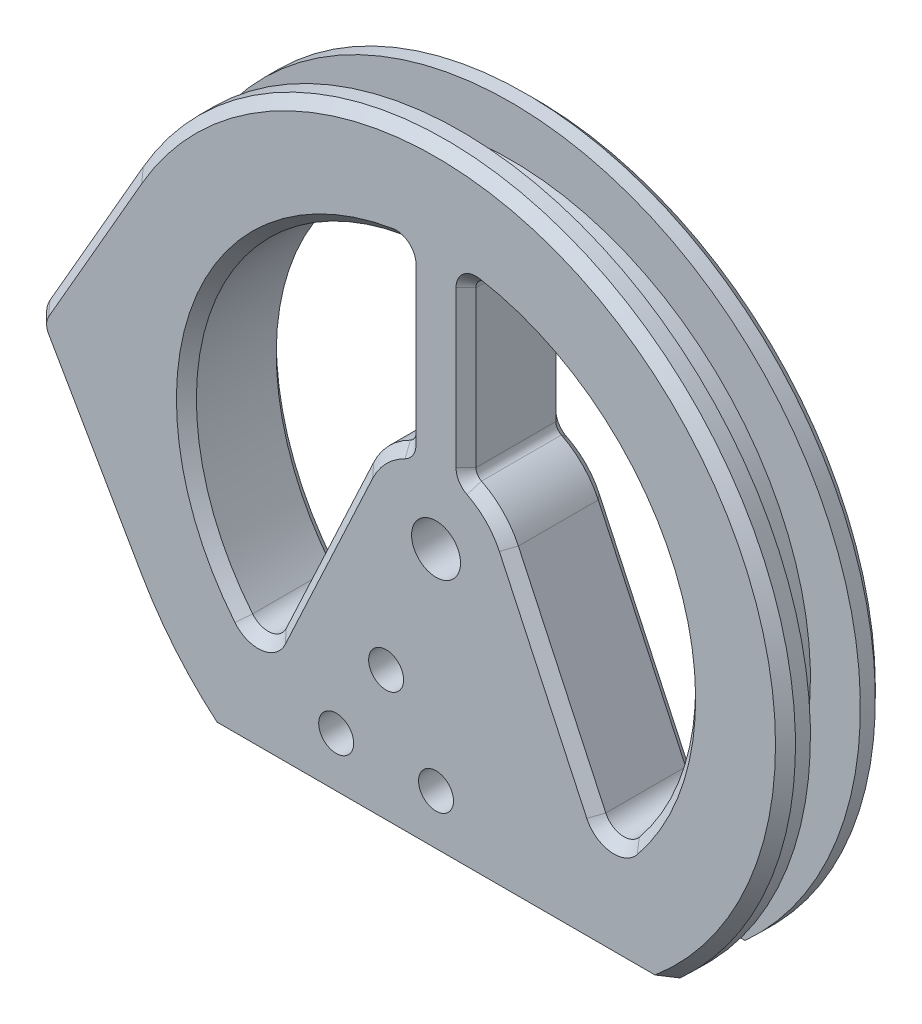
from build123d import *

# Parameters (mm, degrees)
EXTRUDE_1_DEPTH     = 10
SKETCH_2_R          = 2.45
EXTRUDE_2_DEPTH     = 10
SKETCH_3_R          = 1.75
CUT_EXTRUDE_1_DEPTH = 11
EXTRUDE_3_DEPTH     = 2.5
EXTRUDE_4_DEPTH     = 2.5
EXTRUDE_5_REACH     = 9.5
SKETCH_6_R          = 2.5
FILLET_1_R          = 2
SKETCH_7_W          = 6
SKETCH_7_H          = 22
EXTRUDE_6_DEPTH     = 10
FILLET_2_R          = 1
CHAMFER_1_SIZE      = 1
CHAMFER_2_SIZE      = 1
SKETCH_8_R          = 1.75
CUT_EXTRUDE_2_DEPTH = 11


with BuildPart() as part:
    # ｽｹｯﾁ1 → ﾎﾞｽ - 押し出し1 (new body)
    with BuildSketch(Plane.XY):
        with BuildLine():
            Line((-15, -25.980762114), (15, -25.980762114))
            ThreePointArc((15, -25.980762114), (0, 30), (-15, -25.980762114))
        make_face()
        with BuildLine():
            Line((-13.594396682, -20.980762114), (13.594396682, -20.980762114))
            ThreePointArc((13.594396682, -20.980762114), (0, 25), (-13.594396682, -20.980762114))
        make_face(mode=Mode.SUBTRACT)
    extrude(amount=EXTRUDE_1_DEPTH)

    # ｽｹｯﾁ2 → ﾎﾞｽ - 押し出し2 (add)
    with BuildSketch(Plane.XY):
        with BuildLine():
            Line((-13.594396682, -20.980762114), (13.594396682, -20.980762114))
            ThreePointArc((13.594396682, -20.980762114), (15.495156387, -19.618871745), (17.260361171, -18.085351317))
            Line((17.260361171, -18.085351317), (7.250462296, 3.380946094))
            ThreePointArc((7.250462296, 3.380946094), (0, 8), (-7.250462296, 3.380946094))
            Line((-7.250462296, 3.380946094), (-17.260361171, -18.085351317))
            ThreePointArc((-17.260361171, -18.085351317), (-15.495156387, -19.618871745), (-13.594396682, -20.980762114))
        make_face()
        Circle(SKETCH_2_R, mode=Mode.SUBTRACT)
    extrude(amount=EXTRUDE_2_DEPTH)

    # ｽｹｯﾁ3 → ｶｯﾄ - 押し出し1 (cut, through all)
    with BuildSketch(Plane.XY.offset(10)):
        with Locations((0, -20.980762114)):
            Circle(SKETCH_3_R)
        with Locations((-10, -20.980762114)):
            Circle(SKETCH_3_R)
    extrude(amount=-CUT_EXTRUDE_1_DEPTH, mode=Mode.SUBTRACT)

    # ｽｹｯﾁ4 → ﾎﾞｽ - 押し出し3 (add)
    with BuildSketch(Plane.XY):
        with BuildLine():
            Line((-23.452078799, -25.980762114), (-15, -25.980762114))
            ThreePointArc((-15, -25.980762114), (0, 30), (15, -25.980762114))
            Line((15, -25.980762114), (23.452078799, -25.980762114))
            ThreePointArc((23.452078799, -25.980762114), (0, 35), (-23.452078799, -25.980762114))
        make_face()
    extrude_3 = extrude(amount=EXTRUDE_3_DEPTH)

    # ｽｹｯﾁ5 → ﾎﾞｽ - 押し出し4 (add)
    with BuildSketch(Plane.XY):
        with BuildLine():
            Line((-30.333333333, 17.461067805), (-39.666666667, 1.247219129))
            ThreePointArc((-39.666666667, 1.247219129), (-40, 0), (-39.666666667, -1.247219129))
            Line((-39.666666667, -1.247219129), (-30.333333333, -17.461067805))
            Line((-30.333333333, -17.461067805), (-30.333333333, 17.461067805))
        make_face()
    extrude_4 = extrude(amount=EXTRUDE_4_DEPTH)

    # ﾐﾗｰ2: ﾎﾞｽ - 押し出し3, ﾎﾞｽ - 押し出し4 across plane
    add(extrude_3.mirror(Plane(origin=(0, 0, 5), x_dir=(1, 0, 0), z_dir=(0, 0, -1))))
    add(extrude_4.mirror(Plane(origin=(0, 0, 5), x_dir=(1, 0, 0), z_dir=(0, 0, -1))))

    # ｽｹｯﾁ6 → ﾎﾞｽ - 押し出し5 (add, up to next)
    with BuildSketch(Plane.XY.offset(2.5), mode=Mode.PRIVATE) as extrude_5_sk1:
        with Locations((-37.5, 0)):
            Circle(SKETCH_6_R)
    extrude_5_tool1 = extrude(extrude_5_sk1.sketch, amount=EXTRUDE_5_REACH, mode=Mode.PRIVATE) - part.part
    add(extrude_5_tool1.solids().sort_by_distance((-37.5, 0, 2.5))[0])

    # ﾌｨﾚｯﾄ1
    fillet_1_edges = [part.edges().sort_by_distance(p)[0] for p in [
        (-17.260361171, -18.085351317, 5),
        (17.260361171, -18.085351317, 5),
    ]]
    fillet(fillet_1_edges, radius=FILLET_1_R)

    # ｽｹｯﾁ7 → ﾎﾞｽ - 押し出し6 (add)
    with BuildSketch(Plane.XY.offset(10)):
        with Locations((0, 16)):
            Rectangle(SKETCH_7_W, SKETCH_7_H)
    extrude(amount=-EXTRUDE_6_DEPTH)

    # ﾌｨﾚｯﾄ2
    fillet_2_edges = [part.edges().sort_by_distance(p)[0] for p in [
        (3, 7.416198487, 5),
        (-3, 7.416198487, 5),
        (-3, 24.819347292, 5),
        (3, 24.819347292, 5),
    ]]
    fillet(fillet_2_edges, radius=FILLET_2_R)

    # 面取り1
    chamfer_1_edges = [part.edges().sort_by_distance(p)[0] for p in [
        (11.627163615, -6.004920172, 0),
        (11.627163615, -6.004920172, 10),
        (23.403223211, 8.791424421, 0),
        (23.403223211, 8.791424421, 10),
        (17.568783294, -16.530152165, 0),
        (17.568783294, -16.530152165, 10),
        (-17.568783294, -16.530152165, 0),
        (-17.568783294, -16.530152165, 10),
        (-3, 15.86328844, 10),
        (-3, 15.86328844, 0),
        (-23.403223211, 8.791424421, 10),
        (-23.403223211, 8.791424421, 0),
        (3, 15.86328844, 0),
        (3, 15.86328844, 10),
        (-5.724946981, 5.587931824, 10),
        (-5.724946981, 5.587931824, 0),
        (-3.354502776, 24.428081748, 0),
        (-3.354502776, 24.428081748, 10),
        (3.354502776, 24.428081748, 10),
        (3.354502776, 24.428081748, 0),
        (3.150163414, 7.535211472, 10),
        (3.150163414, 7.535211472, 0),
        (-3.150163414, 7.535211472, 0),
        (-3.150163414, 7.535211472, 10),
        (5.724946981, 5.587931824, 10),
        (-11.627163615, -6.004920172, 10),
        (5.724946981, 5.587931824, 0),
        (-11.627163615, -6.004920172, 0),
    ]]
    chamfer(chamfer_1_edges, length=CHAMFER_1_SIZE)

    # 面取り2
    chamfer_2_edges = [part.edges().sort_by_distance(p)[0] for p in [
        (21.991727141, 27.227999143, 0),
        (-27.227999143, -21.991727141, 0),
        (-35, 9.354143467, 0),
        (-40, 0, 0),
        (-35, -9.354143467, 0),
        (21.991727141, 27.227999143, 10),
        (-27.227999143, -21.991727141, 10),
        (-35, 9.354143467, 10),
        (-40, 0, 10),
        (-35, -9.354143467, 10),
    ]]
    chamfer(chamfer_2_edges, length=CHAMFER_2_SIZE)

    # ｽｹｯﾁ8 → ｶｯﾄ - 押し出し2 (cut, through all)
    with BuildSketch(Plane.XY.offset(10)):
        with Locations((-5, -12.980762114)):
            Circle(SKETCH_8_R)
    extrude(amount=-CUT_EXTRUDE_2_DEPTH, mode=Mode.SUBTRACT)


solid = part.part
